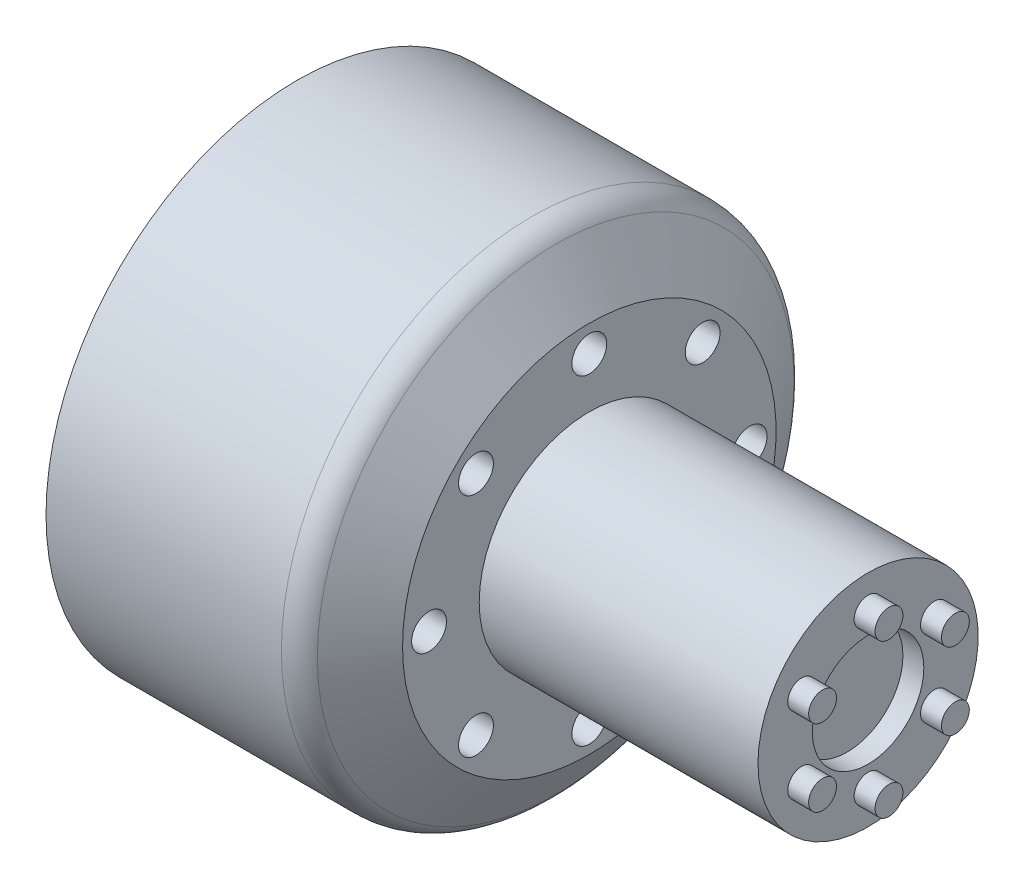
from build123d import *

# Parameters (mm, degrees)
SKETCH2_R           = 1.25
CUT_EXTRUDE1_DEPTH  = 21.98
SKETCH3_R           = 2.5
CUT_EXTRUDE2_DEPTH  = 15.98
SKETCH4_R           = 9.5
CUT_EXTRUDE3_DEPTH  = 10
FILLET2_R           = 2
SKETCH6_R           = 4
CUT_EXTRUDE5_DEPTH  = 1.5
SKETCH7_R           = 1
BOSS_EXTRUDE1_DEPTH = 1.5


with BuildPart() as part:
    # Sketch1 → Revolve1 (revolve)
    with BuildSketch(Plane(origin=(0, 0, 0), x_dir=(1, 0, 0), z_dir=(0, 1, 0))):
        Polygon((7.143835403, 7.9), (7.143835403, 13.4), (4.13367975, 18), (-13.836164597, 18), (-13.836164597, 0), (7.143835403, 0), (27.143835403, 0), (27.143835403, 7.9), align=None)
    revolve(axis=Axis((-26.115988439, 0, 0), (1, 0, 0)))

    # Sketch2 → Cut-Extrude1 (cut, through all)
    with BuildSketch(Plane(origin=(7.143835403, 0, 0), x_dir=(0, 0, -1), z_dir=(1, 0, 0))):
        with Locations((0, 11.5)):
            Circle(SKETCH2_R)
        with Locations((8.131727984, 8.131727984)):
            Circle(SKETCH2_R)
        with Locations((11.5, 0)):
            Circle(SKETCH2_R)
        with Locations((8.131727984, -8.131727984)):
            Circle(SKETCH2_R)
        with Locations((0, -11.5)):
            Circle(SKETCH2_R)
        with Locations((-8.131727984, -8.131727984)):
            Circle(SKETCH2_R)
        with Locations((-11.5, 0)):
            Circle(SKETCH2_R)
        with Locations((-8.131727984, 8.131727984)):
            Circle(SKETCH2_R)
    extrude(amount=-CUT_EXTRUDE1_DEPTH, mode=Mode.SUBTRACT)

    # Sketch3 → Cut-Extrude2 (cut)
    with BuildSketch(Plane.ZY.offset(13.836164597)):
        with Locations((0, 11.5)):
            Circle(SKETCH3_R)
        with Locations((8.131727984, 8.131727984)):
            Circle(SKETCH3_R)
        with Locations((11.5, 0)):
            Circle(SKETCH3_R)
        with Locations((8.131727984, -8.131727984)):
            Circle(SKETCH3_R)
        with Locations((0, -11.5)):
            Circle(SKETCH3_R)
        with Locations((-8.131727984, -8.131727984)):
            Circle(SKETCH3_R)
        with Locations((-11.5, 0)):
            Circle(SKETCH3_R)
        with Locations((-8.131727984, 8.131727984)):
            Circle(SKETCH3_R)
    extrude(amount=-CUT_EXTRUDE2_DEPTH, mode=Mode.SUBTRACT)

    # Sketch4 → Cut-Extrude3 (cut)
    with BuildSketch(Plane.ZY.offset(13.836164597)):
        Circle(SKETCH4_R)
    extrude(amount=-CUT_EXTRUDE3_DEPTH, mode=Mode.SUBTRACT)

    # Fillet2
    fillet2_edges = [part.edges().sort_by_distance(p)[0] for p in [
        (4.13367975, 0, 18),
    ]]
    fillet(fillet2_edges, radius=FILLET2_R)

    # Sketch6 → Cut-Extrude5 (cut)
    with BuildSketch(Plane(origin=(27.143835403, 0, 0), x_dir=(0, 0, -1), z_dir=(1, 0, 0))):
        Circle(SKETCH6_R)
    extrude(amount=-CUT_EXTRUDE5_DEPTH, mode=Mode.SUBTRACT)

    # Sketch7 → Boss-Extrude1 (add)
    with BuildSketch(Plane(origin=(27.143835403, 0, 0), x_dir=(0, 0, -1), z_dir=(1, 0, 0))):
        with Locations((0, 5.5)):
            Circle(SKETCH7_R)
        with Locations((4.763139721, 2.75)):
            Circle(SKETCH7_R)
        with Locations((4.763139721, -2.75)):
            Circle(SKETCH7_R)
        with Locations((0, -5.5)):
            Circle(SKETCH7_R)
        with Locations((-4.763139721, -2.75)):
            Circle(SKETCH7_R)
        with Locations((-4.763139721, 2.75)):
            Circle(SKETCH7_R)
    extrude(amount=BOSS_EXTRUDE1_DEPTH)


solid = part.part
